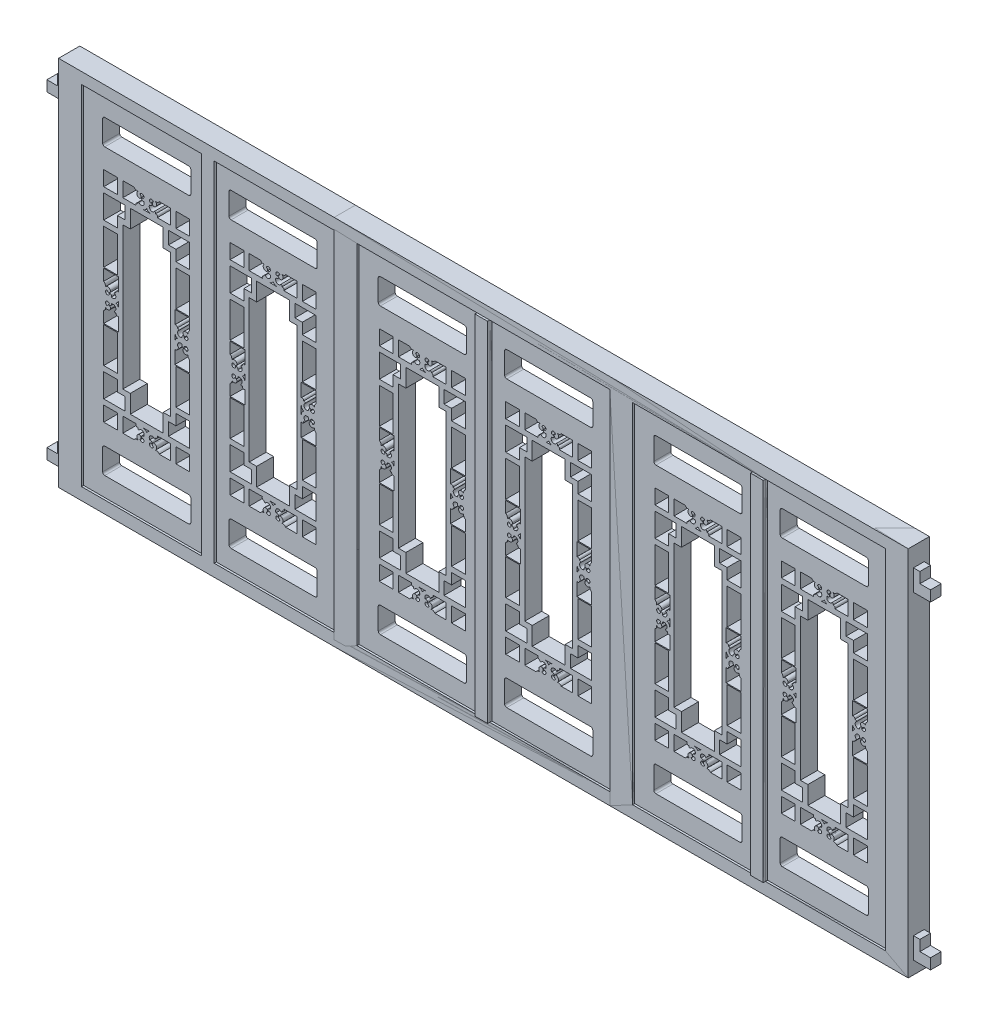
from build123d import *

# Parameters (mm, degrees)
SKETCH1_W                = 595
SKETCH1_H                = 1640
BOSS_EXTRUDE1_DEPTH      = 180
SKETCH_6_W               = 595
SKETCH_6_H               = 1640
CUT_EXTRUDE_2_DEPTH      = 100
CUT_EXTRUDE_3_DEPTH      = 100
SKETCH2_W                = 65
SKETCH2_H                = 70
SKETCH2_H_2              = 167
CUT_EXTRUDE_5_DEPTH      = 1747.432077122
CUT_EXTRUDE_8_DEPTH      = 1747.432077122
PATTERN_LINEAR_1_COUNT   = 2
PATTERN_LINEAR_1_PITCH   = 595
EXTRUDE_2_DEPTH          = 90
EXTRUDE_2_DEPTH_BACK     = 10
SKETCH_7_W               = 4000
SKETCH_7_H               = 1750
SKETCH_7_W_2             = 1190
SKETCH_7_H_2             = 1640
EXTRUDE_3_DEPTH          = 10
EXTRUDE_3_DEPTH_BACK     = 90
SKETCH_9_W               = 60
SKETCH_9_H               = 1640
EXTRUDE_4_DEPTH          = 100
PATTERN_LINEAR_2_COUNT   = 3
PATTERN_LINEAR_2_PITCH   = 1297.5
SKETCH_11_W              = 2595
SKETCH_11_H              = 1750
CUT_EXTRUDE_9_DEPTH      = 6706.543415712
SKETCH_12_W              = 50
SKETCH_12_H              = 100
EXTRUDE_5_DEPTH          = 80
SKETCH_13_W              = 50
SKETCH_13_H              = 50
CUT_EXTRUDE_10_DEPTH     = 50
PATTERN_LINEAR_3_COUNT   = 2
PATTERN_LINEAR_3_PITCH   = 1500
MIRROR_4_COPY_1_SKETCH_W = 50
MIRROR_4_COPY_1_SKETCH_H = 100
MIRROR_4_COPY_1_DEPTH    = 80
MIRROR_4_COPY_2_SKETCH_W = 50
MIRROR_4_COPY_2_SKETCH_H = 50
MIRROR_4_COPY_2_DEPTH    = 50


with BuildPart() as part:
    # Sketch1 → Boss-Extrude1 (new body)
    with BuildSketch(Plane.XY):
        with Locations((297.5, 820)):
            Rectangle(SKETCH1_W, SKETCH1_H)
    extrude(amount=BOSS_EXTRUDE1_DEPTH)

    # 草图6 → 切除-拉伸2 (cut)
    with BuildSketch(Plane.XY.offset(180)):
        with Locations((297.5, 820)):
            Rectangle(SKETCH_6_W, SKETCH_6_H)
    extrude(amount=-CUT_EXTRUDE_2_DEPTH, mode=Mode.SUBTRACT)

    # 草图1 → 切除-拉伸3 (cut)
    with BuildSketch(Plane(origin=(0, 0, 0), x_dir=(-1, 0, 0), z_dir=(0, 0, -1))):
        with BuildLine():
            ThreePointArc((-339.478697135, 363.442307012), (-347.464207716, 366.462464977), (-347.449072001, 375))
            Line((-347.449072001, 375), (-410, 375))
            Line((-410, 375), (-410, 305))
            Line((-410, 305), (-356.673331708, 305))
            ThreePointArc((-356.673331708, 305), (-348.94904931, 312.012889726), (-338.529552639, 312.541330816))
            ThreePointArc((-338.529552639, 312.541330816), (-344.046220029, 325.924483031), (-334.768909443, 337.036363636))
            ThreePointArc((-334.768909443, 337.036363636), (-323.949287324, 331.726907665), (-329.315168468, 320.935157804))
            ThreePointArc((-329.315168468, 320.935157804), (-314.478603669, 315.069270244), (-315.214046212, 331.006378394))
            ThreePointArc((-315.214046212, 331.006378394), (-318.365986632, 330.765395418), (-320.358708006, 328.311447022))
            ThreePointArc((-320.358708006, 328.311447022), (-320.882047686, 338.069212343), (-311.577227356, 341.053870966))
            ThreePointArc((-311.577227356, 341.053870966), (-311.192434776, 341.798442865), (-310.72696898, 342.495432272))
            ThreePointArc((-310.72696898, 342.495432272), (-316.343126273, 360.498534643), (-334.477239272, 355.321000146))
            ThreePointArc((-334.477239272, 355.321000146), (-338.751843962, 358.289222889), (-339.478697135, 363.442307012))
        make_face()
        with BuildLine():
            Line((-279.5, 375), (-315.5, 375))
            ThreePointArc((-315.5, 375), (-304.873925683, 371.412833197), (-297.5, 362.9626))
            ThreePointArc((-297.5, 362.9626), (-290.126074317, 371.412833197), (-279.5, 375))
        make_face()
        with BuildLine():
            Line((-185, 375), (-247.550927999, 375))
            ThreePointArc((-247.550927999, 375), (-247.535792284, 366.462464977), (-255.521302865, 363.442307012))
            ThreePointArc((-255.521302865, 363.442307012), (-256.248156038, 358.289222889), (-260.522760728, 355.321000146))
            ThreePointArc((-260.522760728, 355.321000146), (-278.656873727, 360.498534643), (-284.27303102, 342.495432272))
            ThreePointArc((-284.27303102, 342.495432272), (-283.807565224, 341.798442865), (-283.422772644, 341.053870966))
            ThreePointArc((-283.422772644, 341.053870966), (-274.117952314, 338.069212343), (-274.641291994, 328.311447022))
            ThreePointArc((-274.641291994, 328.311447022), (-276.634013368, 330.765395418), (-279.785953788, 331.006378394))
            ThreePointArc((-279.785953788, 331.006378394), (-280.521396331, 315.069270244), (-265.684831532, 320.935157804))
            ThreePointArc((-265.684831532, 320.935157804), (-271.050712676, 331.726907665), (-260.231090557, 337.036363636))
            ThreePointArc((-260.231090557, 337.036363636), (-250.953779971, 325.924483031), (-256.470447361, 312.541330816))
            ThreePointArc((-256.470447361, 312.541330816), (-246.05095069, 312.012889726), (-238.326668292, 305))
            Line((-238.326668292, 305), (-185, 305))
            Line((-185, 305), (-185, 375))
        make_face()
    cut_extrude_3 = extrude(amount=-CUT_EXTRUDE_3_DEPTH, mode=Mode.SUBTRACT)

    # Sketch2 → 切除-拉伸5 (cut, through all)
    with BuildSketch(Plane(origin=(0, 0, 0), x_dir=(-1, 0, 0), z_dir=(0, 0, -1))):
        with Locations((-467.5, 1300)):
            Rectangle(SKETCH2_W, SKETCH2_H)
        Polygon((-400, 1240), (-500, 1240), (-500, 1129), (-435, 1129), (-435, 1180), (-400, 1180), align=None)
        with Locations((-467.5, 1020.5)):
            Rectangle(SKETCH2_W, SKETCH2_H_2)
        Polygon((-220, 1240), (-375, 1240), (-375, 1155), (-410, 1155), (-410, 485), (-375, 485), (-375, 400), (-220, 400), (-220, 485), (-185, 485), (-185, 1155), (-220, 1155), align=None)
        with Locations((-127.5, 1300)):
            Rectangle(SKETCH2_W, SKETCH2_H)
        Polygon((-95, 1240), (-195, 1240), (-195, 1180), (-160, 1180), (-160, 1129), (-95, 1129), align=None)
        with Locations((-467.5, 619.5)):
            Rectangle(SKETCH2_W, SKETCH2_H_2)
        with Locations((-127.5, 1020.5)):
            Rectangle(SKETCH2_W, SKETCH2_H_2)
        Polygon((-435, 511), (-500, 511), (-500, 400), (-400, 400), (-400, 460), (-435, 460), align=None)
        Polygon((-195, 460), (-195, 400), (-95, 400), (-95, 511), (-160, 511), (-160, 460), align=None)
        with Locations((-467.5, 340)):
            Rectangle(SKETCH2_W, SKETCH2_H)
        with Locations((-127.5, 619.5)):
            Rectangle(SKETCH2_W, SKETCH2_H_2)
        with Locations((-127.5, 340)):
            Rectangle(SKETCH2_W, SKETCH2_H)
        with BuildLine():
            Line((-100, 210), (-495, 210))
            ThreePointArc((-495, 210), (-502.071067812, 207.071067812), (-505, 200))
            Line((-505, 200), (-505, 100))
            ThreePointArc((-505, 100), (-502.071067812, 92.928932188), (-495, 90))
            Line((-495, 90), (-100, 90))
            ThreePointArc((-100, 90), (-92.928932188, 92.928932188), (-90, 100))
            Line((-90, 100), (-90, 200))
            ThreePointArc((-90, 200), (-92.928932188, 207.071067812), (-100, 210))
        make_face()
        with BuildLine():
            Line((-100, 1550), (-495, 1550))
            ThreePointArc((-495, 1550), (-502.071067812, 1547.071067812), (-505, 1540))
            Line((-505, 1540), (-505, 1440))
            ThreePointArc((-505, 1440), (-502.071067812, 1432.928932188), (-495, 1430))
            Line((-495, 1430), (-100, 1430))
            ThreePointArc((-100, 1430), (-92.928932188, 1432.928932188), (-90, 1440))
            Line((-90, 1440), (-90, 1540))
            ThreePointArc((-90, 1540), (-92.928932188, 1547.071067812), (-100, 1550))
        make_face()
    extrude(amount=-CUT_EXTRUDE_5_DEPTH, mode=Mode.SUBTRACT)

    # 镜向1: 切除-拉伸3 across plane
    add(cut_extrude_3.mirror(Plane.ZX.offset(820)), mode=Mode.SUBTRACT)

    # 草图1<5> → 切除-拉伸8 (cut, through all)
    with BuildSketch(Plane(origin=(0, 0, 0), x_dir=(-1, 0, 0), z_dir=(0, 0, -1))):
        with BuildLine():
            Line((-500, 760.826668292), (-500, 707.5))
            Line((-500, 707.5), (-430, 707.5))
            Line((-430, 707.5), (-430, 770.050927999))
            ThreePointArc((-430, 770.050927999), (-438.537535023, 770.035792284), (-441.557692988, 778.021302865))
            ThreePointArc((-441.557692988, 778.021302865), (-446.710777111, 778.748156038), (-449.678999854, 783.022760728))
            ThreePointArc((-449.678999854, 783.022760728), (-444.501465357, 801.156873727), (-462.504567728, 806.77303102))
            ThreePointArc((-462.504567728, 806.77303102), (-463.201557135, 806.307565224), (-463.946129034, 805.922772644))
            ThreePointArc((-463.946129034, 805.922772644), (-466.930787657, 796.617952314), (-476.688552978, 797.141291994))
            ThreePointArc((-476.688552978, 797.141291994), (-474.234604582, 799.134013368), (-473.993621606, 802.285953788))
            ThreePointArc((-473.993621606, 802.285953788), (-489.930729756, 803.021396331), (-484.064842196, 788.184831532))
            ThreePointArc((-484.064842196, 788.184831532), (-473.273092335, 793.550712676), (-467.963636364, 782.731090557))
            ThreePointArc((-467.963636364, 782.731090557), (-479.075516969, 773.453779971), (-492.458669184, 778.970447361))
            ThreePointArc((-492.458669184, 778.970447361), (-492.987110274, 768.55095069), (-500, 760.826668292))
        make_face()
        with BuildLine():
            ThreePointArc((-442.0374, 820), (-433.587166803, 812.626074317), (-430, 802))
            Line((-430, 802), (-430, 838))
            ThreePointArc((-430, 838), (-433.587166803, 827.373925683), (-442.0374, 820))
        make_face()
        with BuildLine():
            Line((-430, 869.949072001), (-430, 932.5))
            Line((-430, 932.5), (-500, 932.5))
            Line((-500, 932.5), (-500, 879.173331708))
            ThreePointArc((-500, 879.173331708), (-492.987110274, 871.44904931), (-492.458669184, 861.029552639))
            ThreePointArc((-492.458669184, 861.029552639), (-479.075516969, 866.546220029), (-467.963636364, 857.268909443))
            ThreePointArc((-467.963636364, 857.268909443), (-473.273092335, 846.449287324), (-484.064842196, 851.815168468))
            ThreePointArc((-484.064842196, 851.815168468), (-489.930729756, 836.978603669), (-473.993621606, 837.714046212))
            ThreePointArc((-473.993621606, 837.714046212), (-474.234604582, 840.865986631), (-476.688552978, 842.858708006))
            ThreePointArc((-476.688552978, 842.858708006), (-466.930787657, 843.382047686), (-463.946129034, 834.077227356))
            ThreePointArc((-463.946129034, 834.077227356), (-463.201557135, 833.692434776), (-462.504567728, 833.22696898))
            ThreePointArc((-462.504567728, 833.22696898), (-444.501465357, 838.843126273), (-449.678999854, 856.977239272))
            ThreePointArc((-449.678999854, 856.977239272), (-446.710777111, 861.251843962), (-441.557692988, 861.978697135))
            ThreePointArc((-441.557692988, 861.978697135), (-438.537535023, 869.964207716), (-430, 869.949072001))
        make_face()
    cut_extrude_8 = extrude(amount=-CUT_EXTRUDE_8_DEPTH, mode=Mode.SUBTRACT)

    # 镜向3: 切除-拉伸8 across plane
    add(cut_extrude_8.mirror(Plane.ZY.offset(-297.5)), mode=Mode.SUBTRACT)


with BuildPart() as pattern_linear_1_1:
    # 阵列(线性)1: pattern copy
    add(part.part.moved(Location(Vector(1, 0, 0) * (1 * PATTERN_LINEAR_1_PITCH))))


with BuildPart() as part_1:
    add(part.part)

    add(pattern_linear_1_1.part)  # 凸台-拉伸2 merges 阵列(线性)1_1
    # 草图7 → 凸台-拉伸2 (add, two sides: drawn at the far end of the back side and taken through both)
    with BuildSketch(Plane.XY.offset(-EXTRUDE_2_DEPTH_BACK)):
        with Locations((1892.5, 817.5)):
            Rectangle(SKETCH_7_W, SKETCH_7_H)
        with Locations((1892.5, 820)):
            Rectangle(SKETCH_7_W_2, SKETCH_7_H_2, mode=Mode.SUBTRACT)
        with Locations((595, 820)):
            Rectangle(SKETCH_7_W_2, SKETCH_7_H_2, mode=Mode.SUBTRACT)
        with Locations((3190, 820)):
            Rectangle(SKETCH_7_W_2, SKETCH_7_H_2, mode=Mode.SUBTRACT)
    extrude(amount=EXTRUDE_2_DEPTH + EXTRUDE_2_DEPTH_BACK)

    # 草图8 → 凸台-拉伸3 (add, two sides: drawn at the far end of the back side and taken through both)
    with BuildSketch(Plane(origin=(0, 0, 0), x_dir=(-1, 0, 0), z_dir=(0, 0, -1)).offset(-EXTRUDE_3_DEPTH_BACK)):
        Polygon((-595, 1640), (-565, 1640), (-565, 0), (-625, 0), (-625, 1640), align=None)
    extrude(amount=EXTRUDE_3_DEPTH + EXTRUDE_3_DEPTH_BACK)

    # 草图9 → 凸台-拉伸4 (add)
    with BuildSketch(Plane.XY):
        with Locations((1892.5, 820)):
            Rectangle(SKETCH_9_W, SKETCH_9_H)
        with Locations((3190, 820)):
            Rectangle(SKETCH_9_W, SKETCH_9_H)
    extrude(amount=EXTRUDE_4_DEPTH)


with BuildPart() as pattern_linear_2_1:
    # 阵列(线性)2: pattern copy
    add(part_1.part.moved(Location(Vector(1, 0, 0) * (1 * PATTERN_LINEAR_2_PITCH))))


with BuildPart() as pattern_linear_2_2:
    # 阵列(线性)2: pattern copy
    add(part_1.part.moved(Location(Vector(1, 0, 0) * (2 * PATTERN_LINEAR_2_PITCH))))


with BuildPart() as cut_extrude_9_tool:
    # 草图11 → 切除-拉伸9 (new, through all)
    with BuildSketch(Plane.XY.offset(100)):
        with Locations((5190, 817.5)):
            Rectangle(SKETCH_11_W, SKETCH_11_H)
    extrude(amount=-CUT_EXTRUDE_9_DEPTH)


with BuildPart() as pattern_linear_2_1_1:
    add(pattern_linear_2_1.part)

    # 切除-拉伸9: cut by cut_extrude_9_tool
    add(cut_extrude_9_tool.part, mode=Mode.SUBTRACT)


with BuildPart() as pattern_linear_2_2_1:
    add(pattern_linear_2_2.part)

    # 切除-拉伸9: cut by cut_extrude_9_tool
    add(cut_extrude_9_tool.part, mode=Mode.SUBTRACT)


with BuildPart() as part_2:
    add(part_1.part)

    # 草图12 → 凸台-拉伸5 (add)
    with BuildSketch(Plane.ZY.offset(107.5)):
        with Locations((40, 52.5)):
            Rectangle(SKETCH_12_W, SKETCH_12_H)
    extrude_5 = extrude(amount=EXTRUDE_5_DEPTH)

    # 草图13 → 切除-拉伸10 (cut)
    with BuildSketch(Plane.ZY.offset(187.5)):
        with Locations((40, 77.5)):
            Rectangle(SKETCH_13_W, SKETCH_13_H)
    cut_extrude_10 = extrude(amount=-CUT_EXTRUDE_10_DEPTH, mode=Mode.SUBTRACT)

    # 阵列(线性)3: 凸台-拉伸5, 切除-拉伸10 ×2
    with Locations(*[(0, i * PATTERN_LINEAR_3_PITCH, 0) for i in range(1, PATTERN_LINEAR_3_COUNT)]):
        add(extrude_5)
        add(cut_extrude_10, mode=Mode.SUBTRACT)

    # 镜向4: 凸台-拉伸5, 切除-拉伸10 across plane
    add(extrude_5.mirror(Plane(origin=(1892.5, -57.5, 90), x_dir=(0, 0, 1), z_dir=(-1, 0, 0))))
    add(cut_extrude_10.mirror(Plane(origin=(1892.5, -57.5, 90), x_dir=(0, 0, 1), z_dir=(-1, 0, 0))), mode=Mode.SUBTRACT)

    # 镜向4 copy 1 sketch → 镜向4 copy 1 (add)
    with BuildSketch(Plane(origin=(3892.5, 1500, 0), x_dir=(0, 0, 1), z_dir=(1, 0, 0))):
        with Locations((40, -52.5)):
            Rectangle(MIRROR_4_COPY_1_SKETCH_W, MIRROR_4_COPY_1_SKETCH_H)
    extrude(amount=MIRROR_4_COPY_1_DEPTH)

    # 镜向4 copy 2 sketch → 镜向4 copy 2 (cut)
    with BuildSketch(Plane(origin=(3972.5, 1500, 0), x_dir=(0, 0, 1), z_dir=(1, 0, 0))):
        with Locations((40, -77.5)):
            Rectangle(MIRROR_4_COPY_2_SKETCH_W, MIRROR_4_COPY_2_SKETCH_H)
    extrude(amount=-MIRROR_4_COPY_2_DEPTH, mode=Mode.SUBTRACT)


solid = Compound([pattern_linear_2_1_1.part, pattern_linear_2_2_1.part, part_2.part])
